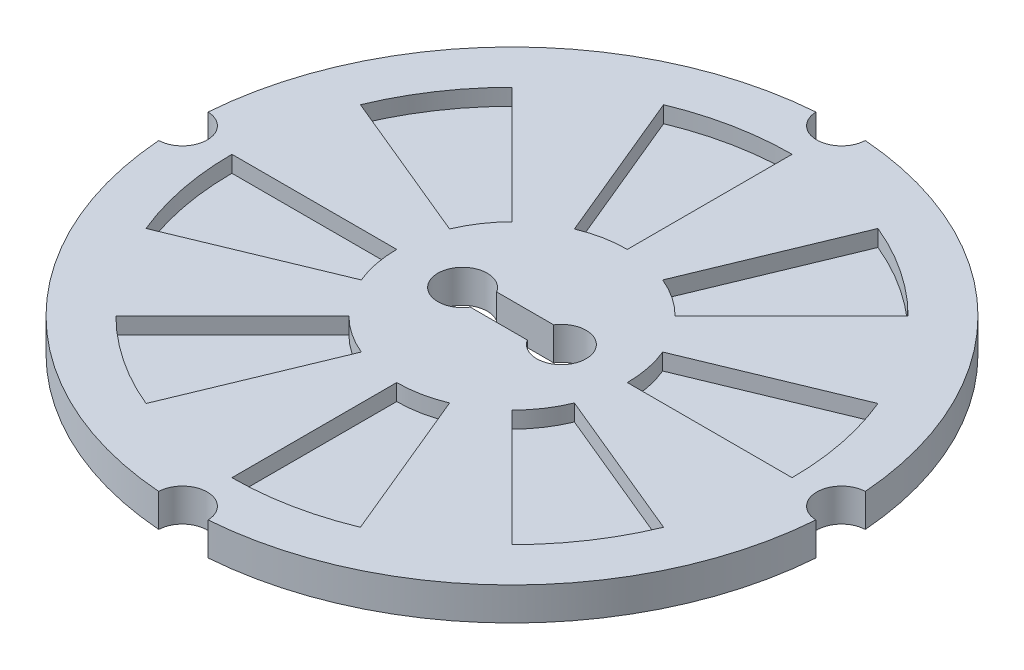
from build123d import *

# Parameters (mm, degrees)
SKETCH1_R           = 127
BOSS_EXTRUDE1_DEPTH = 12.7
CUT_EXTRUDE1_DEPTH  = 6.35
SKETCH2_3_R         = 9.525
CUT_EXTRUDE2_DEPTH  = 181.05357536


with BuildPart() as part:
    # Sketch1 → Boss-Extrude1 (new body)
    with BuildSketch(Plane(origin=(0, 0, 0), x_dir=(1, 0, 0), z_dir=(0, 1, 0))):
        Circle(SKETCH1_R)
    extrude(amount=BOSS_EXTRUDE1_DEPTH)

    # Sketch2 → Cut-Extrude1 (cut)
    with BuildSketch(Plane(origin=(0, 12.7, 0), x_dir=(1, 0, 0), z_dir=(0, 1, 0))):
        with BuildLine():
            Line((99.732795535, 41.310676524), (41.06644522, 17.010278569))
            ThreePointArc((41.06644522, 17.010278569), (43.595905714, 8.671764814), (44.45, 0))
            Line((44.45, 0), (107.95, 0))
            ThreePointArc((107.95, 0), (105.87577102, 21.060000262), (99.732795535, 41.310676524))
        make_face()
        with BuildLine():
            Line((99.732795535, -41.310676524), (41.06644522, -17.010278569))
            ThreePointArc((41.06644522, -17.010278569), (36.958824267, -24.695096858), (31.430896424, -31.430896424))
            Line((31.430896424, -31.430896424), (76.332177029, -76.332177029))
            ThreePointArc((76.332177029, -76.332177029), (89.757144648, -59.973806654), (99.732795535, -41.310676524))
        make_face()
        with BuildLine():
            Line((41.310676524, -99.732795535), (17.010278569, -41.06644522))
            ThreePointArc((17.010278569, -41.06644522), (8.671764814, -43.595905714), (0, -44.45))
            Line((0, -44.45), (0, -107.95))
            ThreePointArc((0, -107.95), (21.060000262, -105.87577102), (41.310676524, -99.732795535))
        make_face()
        with BuildLine():
            Line((-41.310676524, -99.732795535), (-17.010278569, -41.06644522))
            ThreePointArc((-17.010278569, -41.06644522), (-24.695096858, -36.958824267), (-31.430896424, -31.430896424))
            Line((-31.430896424, -31.430896424), (-76.332177029, -76.332177029))
            ThreePointArc((-76.332177029, -76.332177029), (-59.973806654, -89.757144648), (-41.310676524, -99.732795535))
        make_face()
        with BuildLine():
            Line((-99.732795535, -41.310676524), (-41.06644522, -17.010278569))
            ThreePointArc((-41.06644522, -17.010278569), (-43.595905714, -8.671764814), (-44.45, 0))
            Line((-44.45, 0), (-107.95, 0))
            ThreePointArc((-107.95, 0), (-105.87577102, -21.060000262), (-99.732795535, -41.310676524))
        make_face()
        with BuildLine():
            Line((-99.732795535, 41.310676524), (-41.06644522, 17.010278569))
            ThreePointArc((-41.06644522, 17.010278569), (-36.958824267, 24.695096858), (-31.430896424, 31.430896424))
            Line((-31.430896424, 31.430896424), (-76.332177029, 76.332177029))
            ThreePointArc((-76.332177029, 76.332177029), (-89.757144648, 59.973806654), (-99.732795535, 41.310676524))
        make_face()
        with BuildLine():
            Line((-41.310676524, 99.732795535), (-17.010278569, 41.06644522))
            ThreePointArc((-17.010278569, 41.06644522), (-8.671764814, 43.595905714), (0, 44.45))
            Line((0, 44.45), (0, 107.95))
            ThreePointArc((0, 107.95), (-21.060000262, 105.87577102), (-41.310676524, 99.732795535))
        make_face()
        with BuildLine():
            Line((41.310676524, 99.732795535), (17.010278569, 41.06644522))
            ThreePointArc((17.010278569, 41.06644522), (24.695096858, 36.958824267), (31.430896424, 31.430896424))
            Line((31.430896424, 31.430896424), (76.332177029, 76.332177029))
            ThreePointArc((76.332177029, 76.332177029), (59.973806654, 89.757144648), (41.310676524, 99.732795535))
        make_face()
    extrude(amount=-CUT_EXTRUDE1_DEPTH, mode=Mode.SUBTRACT)

    # Sketch2_3 → Cut-Extrude2 (cut, through all)
    with BuildSketch(Plane(origin=(0, 12.7, 0), x_dir=(1, 0, 0), z_dir=(0, 1, 0))):
        with BuildLine():
            Line((-10.992753262, -5.08), (10.992753262, -5.08))
            ThreePointArc((10.992753262, -5.08), (28.575, 0), (10.992753262, 5.08))
            Line((10.992753262, 5.08), (-10.992753262, 5.08))
            ThreePointArc((-10.992753262, 5.08), (-28.575, 0), (-10.992753262, -5.08))
        make_face()
        with BuildLine():
            ThreePointArc((9.518300378, 126.6428125), (0, 127), (-9.518300378, 126.6428125))
            ThreePointArc((-9.518300378, 126.6428125), (0, 117.475), (9.518300378, 126.6428125))
        make_face()
        with Locations((-127, 0)):
            Circle(SKETCH2_3_R)
        with BuildLine():
            ThreePointArc((126.6428125, -9.518300378), (127, 0), (126.6428125, 9.518300378))
            ThreePointArc((126.6428125, 9.518300378), (117.475, 0), (126.6428125, -9.518300378))
        make_face()
        with BuildLine():
            ThreePointArc((9.518300378, -126.6428125), (0, -117.475), (-9.518300378, -126.6428125))
            ThreePointArc((-9.518300378, -126.6428125), (0, -127), (9.518300378, -126.6428125))
        make_face()
    extrude(amount=-CUT_EXTRUDE2_DEPTH, mode=Mode.SUBTRACT)


solid = part.part
